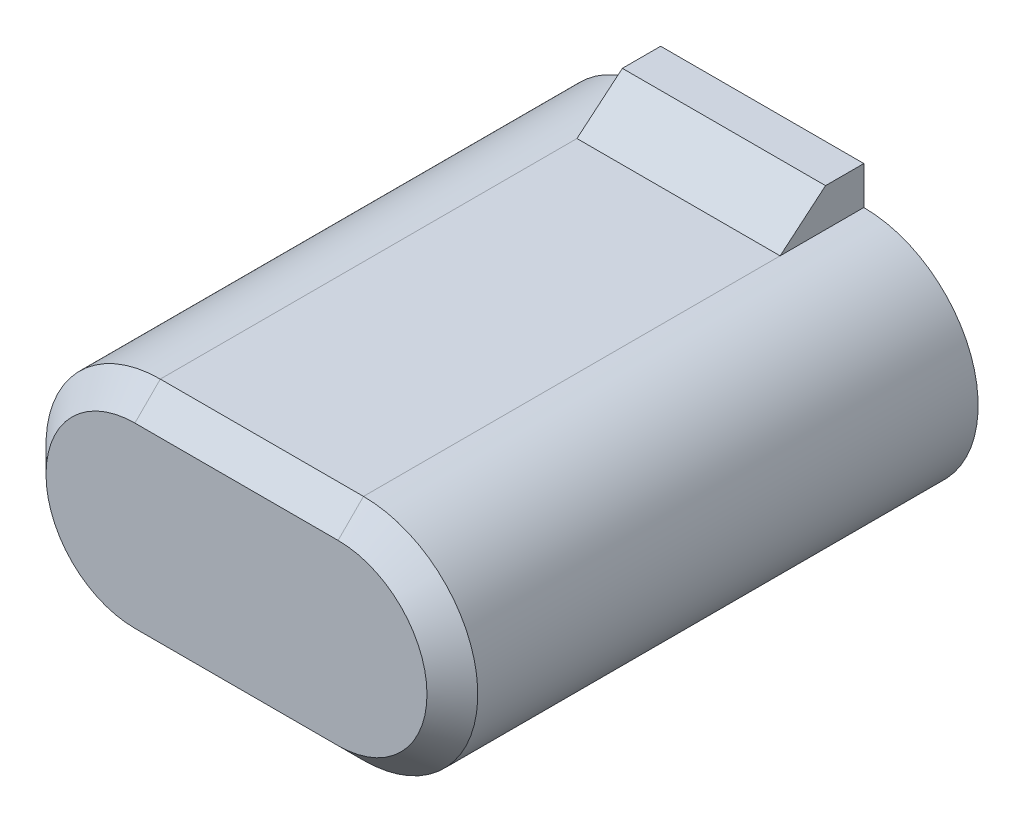
from build123d import *

# Parameters (mm, degrees)
BOSS_EXTRUDE1_DEPTH      = 10.35
BOSS_EXTRUDE2_DEPTH      = 2
BOSS_EXTRUDE2_DEPTH_BACK = 2
CHAMFER1_SIZE            = 0.5


with BuildPart() as part:
    # Sketch2 → Boss-Extrude1 (new body)
    with BuildSketch(Plane.XY):
        with BuildLine():
            Line((-2, 2.25), (2, 2.25))
            ThreePointArc((2, 2.25), (4.25, 0), (2, -2.25))
            Line((2, -2.25), (-2, -2.25))
            ThreePointArc((-2, -2.25), (-4.25, 0), (-2, 2.25))
        make_face()
    extrude(amount=BOSS_EXTRUDE1_DEPTH)

    # Sketch5 → Boss-Extrude2 (add, two sides)
    with BuildSketch(Plane(origin=(0, 0, 0), x_dir=(0, 0, -1), z_dir=(1, 0, 0))) as boss_extrude2_sk:
        Polygon((-1.647938398, 2.25), (-0.754123204, 3), (0, 3), (0, 2.25), align=None)
        Polygon((-1.647938398, -2.25), (0, -2.25), (0, -3), (-0.754123204, -3), align=None)
    extrude(amount=BOSS_EXTRUDE2_DEPTH)
    extrude(boss_extrude2_sk.sketch, amount=-BOSS_EXTRUDE2_DEPTH_BACK)

    # Chamfer1
    chamfer1_edges = [part.edges().sort_by_distance(p)[0] for p in [
        (4.25, 0, 10.35),
        (0, 2.25, 10.35),
        (-4.25, 0, 10.35),
        (0, -2.25, 10.35),
    ]]
    chamfer(chamfer1_edges, length=CHAMFER1_SIZE)


solid = part.part
